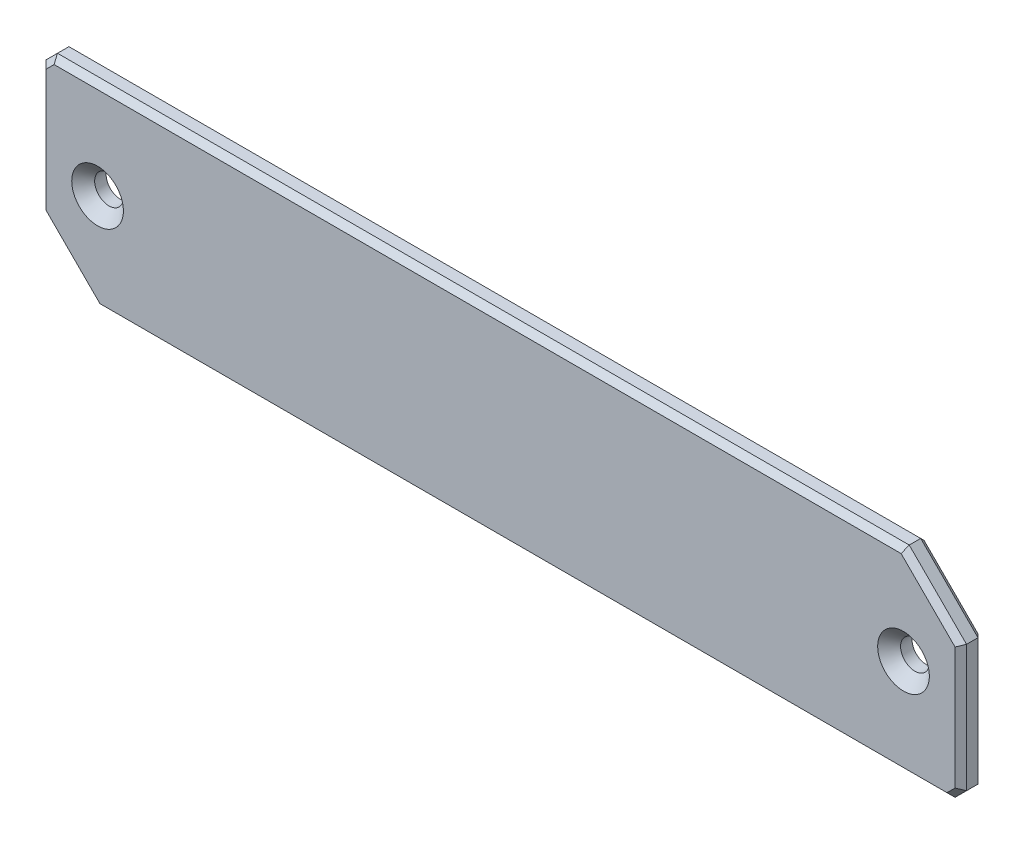
from build123d import *

# Parameters (mm, degrees)
SKETCH_1_R      = 1.254908563
EXTRUDE_1_DEPTH = 2
CHAMFER_1_SIZE  = 1
CHAMFER_3_SIZE  = 0.5
CHAMFER_4_SIZE  = 0.5


with BuildPart() as part:
    # 草图1 → 凸台-拉伸1 (new body)
    with BuildSketch(Plane.XY):
        Polygon((-65.859878879, 17.884443478), (-64.859878879, 18.884443478), (9.454269131, 18.884443478), (14.454269131, 13.884443478), (14.454269131, 2.817687026), (13.454269131, 1.817687026), (-60.859878879, 1.817687026), (-65.859878879, 6.817687026), align=None)
        with Locations((-60.859878879, 10.351065252)):
            Circle(SKETCH_1_R, mode=Mode.SUBTRACT)
        with Locations((9.454269131, 10.351065252)):
            Circle(SKETCH_1_R, mode=Mode.SUBTRACT)
    extrude(amount=EXTRUDE_1_DEPTH)

    # 倒角1
    chamfer_1_edges = [part.edges().sort_by_distance(p)[0] for p in [
        (-62.114787442, 10.351065252, 2),
        (8.199360568, 10.351065252, 2),
    ]]
    chamfer(chamfer_1_edges, length=CHAMFER_1_SIZE)

    # 倒角3
    chamfer_3_edges = [part.edges().sort_by_distance(p)[0] for p in [
        (-65.859878879, 12.351065252, 2),
        (-63.359878879, 4.317687026, 2),
        (-23.702804874, 1.817687026, 2),
        (13.954269131, 2.317687026, 2),
        (14.454269131, 8.351065252, 2),
        (11.954269131, 16.384443478, 2),
        (-27.702804874, 18.884443478, 2),
        (-65.359878879, 18.384443478, 2),
    ]]
    chamfer(chamfer_3_edges, length=CHAMFER_3_SIZE)

    # 倒角4
    chamfer_4_edges = [part.edges().sort_by_distance(p)[0] for p in [
        (-65.359878879, 18.384443478, 0),
        (-27.702804874, 18.884443478, 0),
        (11.954269131, 16.384443478, 0),
        (14.454269131, 8.351065252, 0),
        (13.954269131, 2.317687026, 0),
        (-23.702804874, 1.817687026, 0),
        (-63.359878879, 4.317687026, 0),
        (-65.859878879, 12.351065252, 0),
    ]]
    chamfer(chamfer_4_edges, length=CHAMFER_4_SIZE)


solid = part.part
